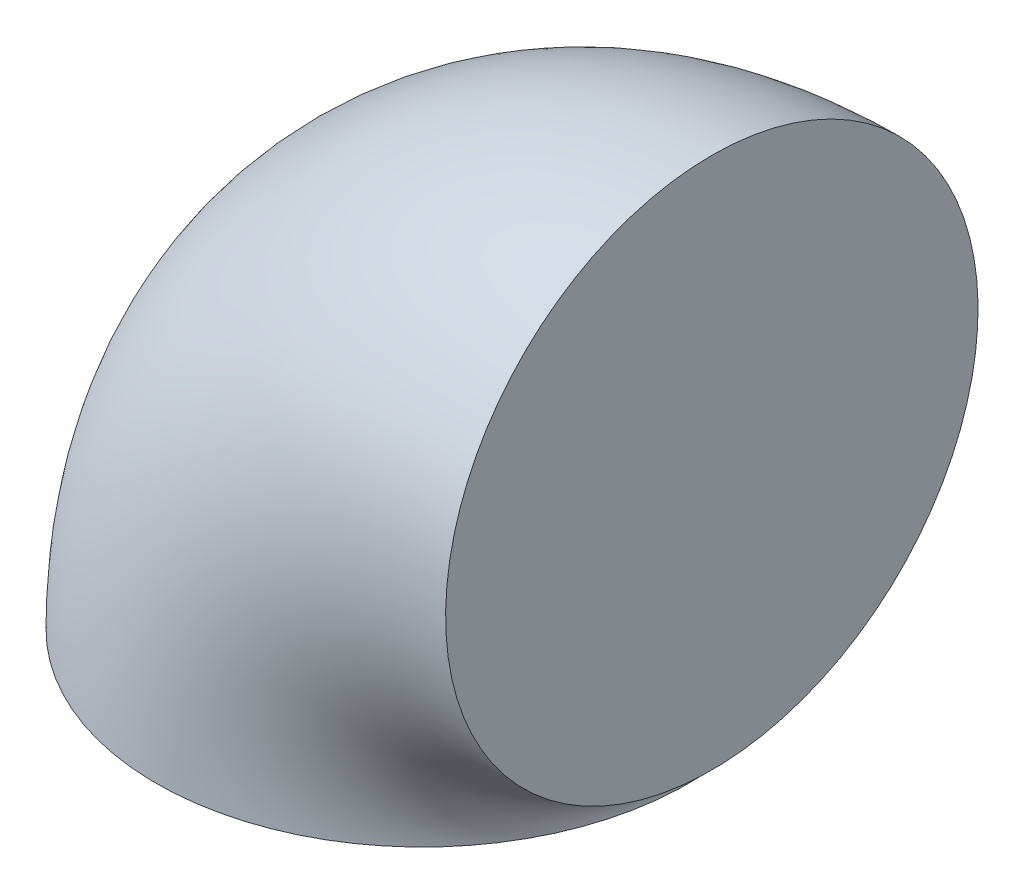
from build123d import *

# Parameters (mm, degrees)
ESBO_O1_R       = 49.5
REVOLU_O1_ANGLE = 90


with BuildPart() as part:
    # Esboço1 → Revolução1 (revolve)
    with BuildSketch(Plane(origin=(0, 0, 0), x_dir=(1, 0, 0), z_dir=(0, 1, 0))):
        Circle(ESBO_O1_R)
    revolve(axis=Axis((53.8, 0, 0), (0, 0, -1)), revolution_arc=REVOLU_O1_ANGLE)


solid = part.part
